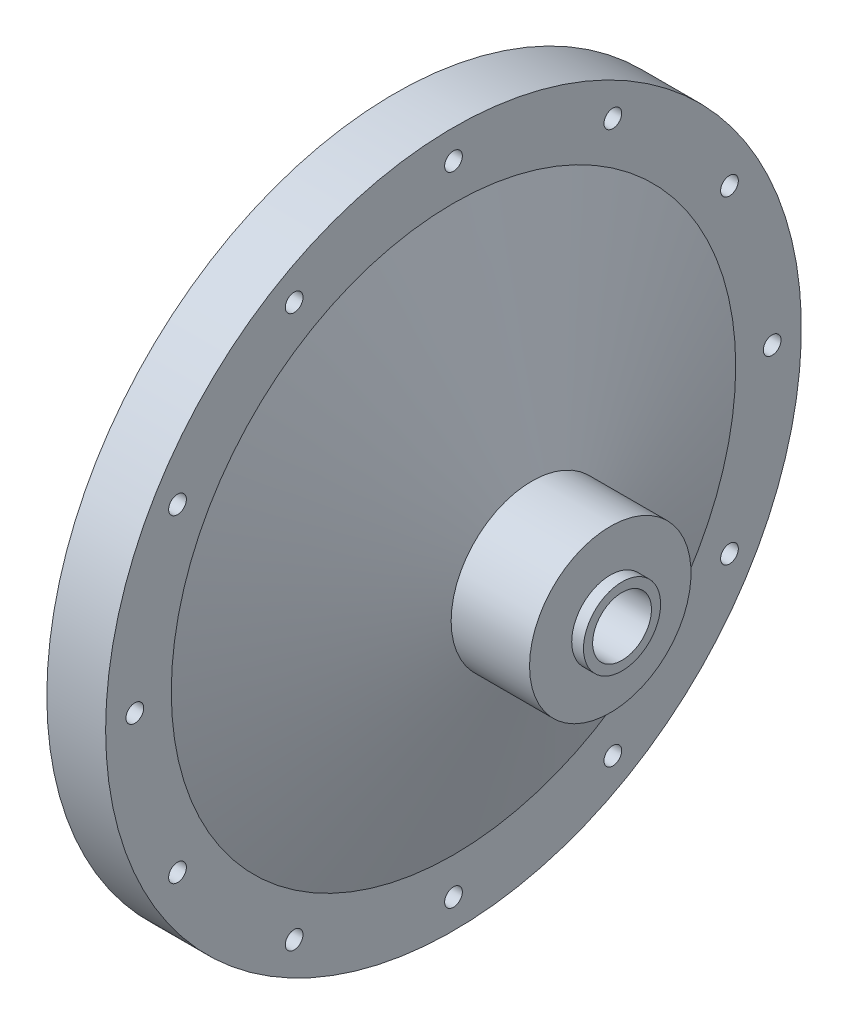
from build123d import *

# Parameters (mm, degrees)
SKETCH3_R                       = 4.7625
OXIDIZER_INLET_HOLE_DEPTH       = 88.798079296
FLANGE_HOLES_D                  = 2.8702
DOWEL_HOLES_D                   = 4.7625
DOWEL_HOLES_DEPTH               = 6.35
DOWEL_HOLES_TIP                 = 1.430799349
SKETCH12_R                      = 38.1
IMPINGING_PLATE_FLAT_CUT_DEPTH  = 3.81
SKETCH14_R                      = 38.1
SKETCH15_R                      = 38.1
SKETCH16_R                      = 28.575
SKETCH17_R                      = 4.7625
INTERNAL_FILLET_R               = 3.175
EXTENDED_8_BC_COUNT             = 8
CHAMFER_FOR_IMPINGING_EDGE_SIZE = 0.127


with BuildPart() as part:
    # Sketch2 → Main Structure (revolve)
    with BuildSketch(Plane.XY, mode=Mode.PRIVATE) as main_structure_sk:
        Polygon((0, 0), (0, 56.35625), (9.525, 56.35625), (9.525, 45.72), (22.225, 13.081), (34.925, 13.081), (34.925, 6.2484), (36.83, 6.2484), (36.83, 0), align=None)
    revolve(main_structure_sk.sketch.rotate(Axis((0, 0, 0), (1, 0, 0)), 90), axis=Axis((0, 0, 0), (1, 0, 0)))

    # Sketch3 → Oxidizer Inlet Hole (cut, through all)
    with BuildSketch(Plane(origin=(36.83, 0, 0), x_dir=(0, 0, -1), z_dir=(1, 0, 0))):
        Circle(SKETCH3_R)
    extrude(amount=-OXIDIZER_INLET_HOLE_DEPTH, mode=Mode.SUBTRACT)

    # Flange Holes (through all)
    with Locations(Plane.ZY):
        with Locations((0, -51.6255), (-25.81275, -44.708994483), (-44.708994483, -25.81275), (-51.6255, 0), (-44.708994483, 25.81275), (-25.81275, 44.708994483), (0, 51.6255), (25.81275, 44.708994483), (44.708994483, 25.81275), (51.6255, 0), (44.708994483, -25.81275), (25.81275, -44.708994483)):
            Hole(FLANGE_HOLES_D / 2)

    # Dowel Holes
    with Locations(Plane.ZY):
        with Locations((49.866403745, -13.361662613), (-49.866403745, 13.361662613)):
            Hole(DOWEL_HOLES_D / 2, depth=DOWEL_HOLES_DEPTH)
            with Locations((0, 0, -(DOWEL_HOLES_DEPTH + DOWEL_HOLES_TIP / 2))):  # 118° drill point
                Cone(0, DOWEL_HOLES_D / 2, DOWEL_HOLES_TIP, mode=Mode.SUBTRACT)

    # Sketch12 → Impinging Plate Flat Cut (cut)
    with BuildSketch(Plane.ZY):
        Circle(SKETCH12_R)
    extrude(amount=-IMPINGING_PLATE_FLAT_CUT_DEPTH, mode=Mode.SUBTRACT)

    # Sketch14 → Impinging Plate Taper Cut section 0
    with BuildSketch(Plane.ZY.offset(-3.81)):
        Circle(SKETCH14_R)
    # Sketch15 → Impinging Plate Taper Cut section 1
    with BuildSketch(Plane.ZY.offset(-6.35)):
        Circle(SKETCH15_R)
    loft(mode=Mode.SUBTRACT)

    # Sketch16 → Internal Flow Path Loft Cut section 0
    with BuildSketch(Plane.ZY.offset(-6.35)):
        Circle(SKETCH16_R)
    # Sketch17 → Internal Flow Path Loft Cut section 1
    with BuildSketch(Plane.ZY.offset(-21.59)):
        Circle(SKETCH17_R)
    loft(mode=Mode.SUBTRACT)

    # Internal Fillet
    internal_fillet_edges = [part.edges().sort_by_distance(p)[0] for p in [
        (21.59, 4.7625, 0),
    ]]
    fillet(internal_fillet_edges, radius=INTERNAL_FILLET_R)

    # Sketch20 → 4-40 Tapped Holes (revolve, cut)
    with BuildSketch(Plane(origin=(6.35, 0, 33.3375), x_dir=(0, 0, 1), z_dir=(0, 1, 0))):
        Polygon((0, 0), (0, 3.854152758), (1.1303, 3.175), (1.1303, 0), align=None)
    f_4_40_tapped_holes = revolve(axis=Axis((0, 0, 33.3375), (1, 0, 0)), mode=Mode.SUBTRACT)

    # Extended 8 BC: 4-40 Tapped Holes ×8 about axis
    extended_8_bc_axis = Axis((0, 0, 0), (1, 0, 0))
    for i in range(1, EXTENDED_8_BC_COUNT):
        add(f_4_40_tapped_holes.rotate(extended_8_bc_axis, i * 360 / EXTENDED_8_BC_COUNT), mode=Mode.SUBTRACT)

    # Chamfer for Impinging Edge
    chamfer_for_impinging_edge_edges = [part.edges().sort_by_distance(p)[0] for p in [
        (6.35, 0, -38.1),
    ]]
    chamfer(chamfer_for_impinging_edge_edges, length=CHAMFER_FOR_IMPINGING_EDGE_SIZE)


solid = part.part
